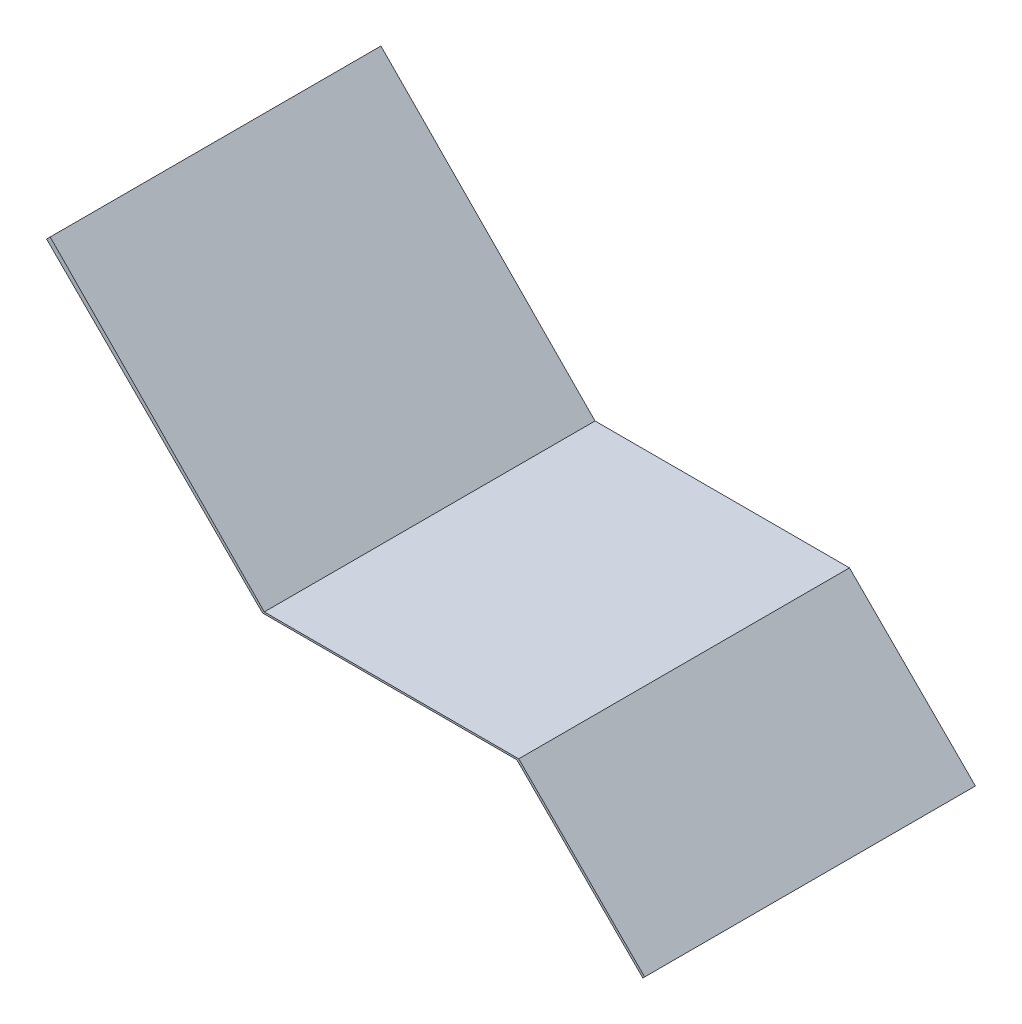
from build123d import *

# Parameters (mm, degrees)
EXTRUDE_1_DEPTH = 650


with BuildPart() as part:
    # 草图1 → 凸台-拉伸1 (new body)
    with BuildSketch(Plane.XY):
        Polygon((-66.511588585, 45.676633124), (357.752480127, -378.587435588), (857.752480127, -378.587435588), (1105.239853543, -626.074809003), (1108.775387449, -622.539275097), (861.288014033, -375.051901682), (361.288014033, -375.051901682), (-59.465382374, 52.722839335), align=None)
    extrude(amount=EXTRUDE_1_DEPTH)


solid = part.part
